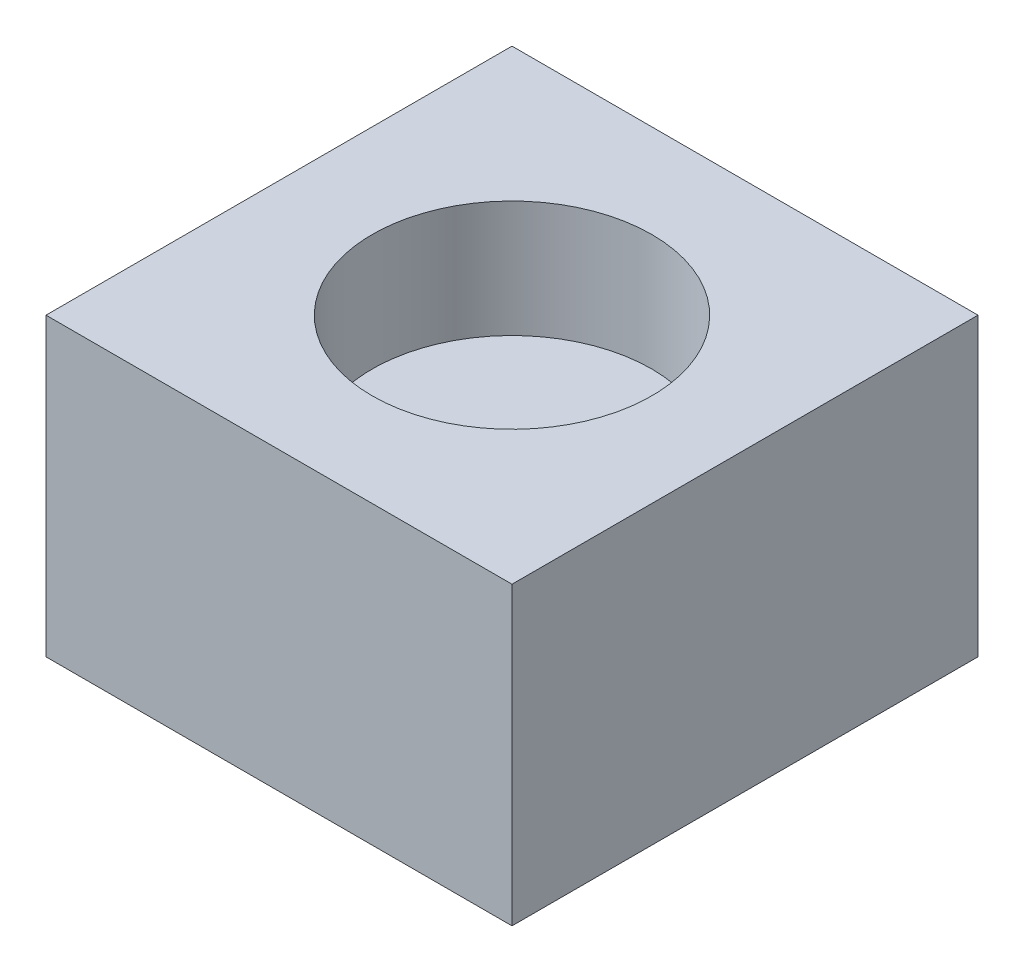
from build123d import *

# Parameters (mm, degrees)
SKETCH1_W           = 10
SKETCH1_H           = 10
BOSS_EXTRUDE1_DEPTH = 6.35
SKETCH2_R           = 3
CUT_EXTRUDE1_DEPTH  = 2.5


with BuildPart() as part:
    # Sketch1 → Boss-Extrude1 (new body)
    with BuildSketch(Plane(origin=(0, 0, 0), x_dir=(1, 0, 0), z_dir=(0, 1, 0))):
        with Locations((5, 5)):
            Rectangle(SKETCH1_W, SKETCH1_H)
    extrude(amount=BOSS_EXTRUDE1_DEPTH)

    # Sketch2 → Cut-Extrude1 (cut)
    with BuildSketch(Plane(origin=(0, 6.35, 0), x_dir=(1, 0, 0), z_dir=(0, 1, 0))):
        with Locations((5, 5)):
            Circle(SKETCH2_R)
    extrude(amount=-CUT_EXTRUDE1_DEPTH, mode=Mode.SUBTRACT)


solid = part.part
